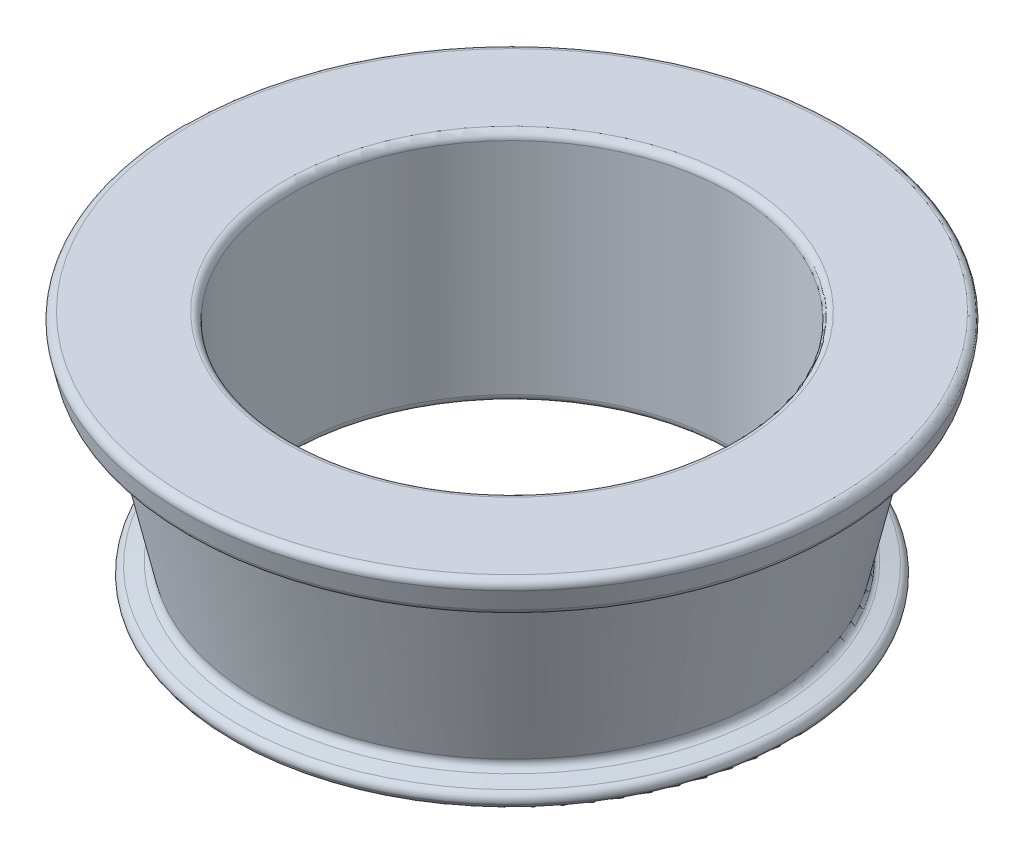
from build123d import *

# Parameters (mm, degrees)
FILLET1_R = 0.5
FILLET2_R = 0.5


with BuildPart() as part:
    # Sketch1 → Revolve1 (revolve)
    with BuildSketch(Plane.XY):
        Polygon((-15, 0), (-15, 16), (-22.6, 16), (-22.050384489, 13.56116364), (-20.099315401, 14.000856049), (-17.248483999, 1.350719466), (-19.248483999, 0.9), (-19, 0), align=None)
    revolve(axis=Axis((0, 0, 0), (0, 1, 0)))

    # Fillet1
    fillet1_edges = [part.edges().sort_by_distance(p)[0] for p in [
        (15, 16, 0),
        (15, 0, 0),
    ]]
    fillet(fillet1_edges, radius=FILLET1_R)

    # Fillet2
    fillet2_edges = [part.edges().sort_by_distance(p)[0] for p in [
        (19, 0, 0),
        (19.248483999, 0.9, 0),
        (17.248483999, 1.350719466, 0),
        (20.099315401, 14.000856049, 0),
        (22.050384489, 13.56116364, 0),
        (22.6, 16, 0),
    ]]
    fillet(fillet2_edges, radius=FILLET2_R)


solid = part.part
